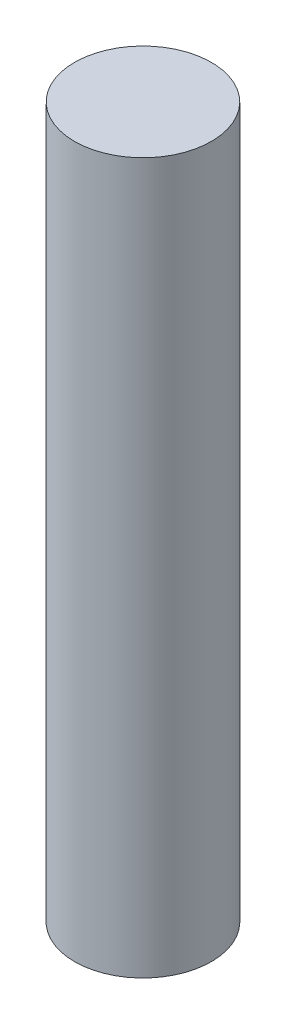
from build123d import *

# Parameters (mm, degrees)
SKETCH1_R           = 4.3815
BOSS_EXTRUDE1_DEPTH = 45.466


with BuildPart() as part:
    # Sketch1 → Boss-Extrude1 (new body)
    with BuildSketch(Plane(origin=(0, 0, 0), x_dir=(1, 0, 0), z_dir=(0, 1, 0))):
        Circle(SKETCH1_R)
    extrude(amount=BOSS_EXTRUDE1_DEPTH)


solid = part.part
